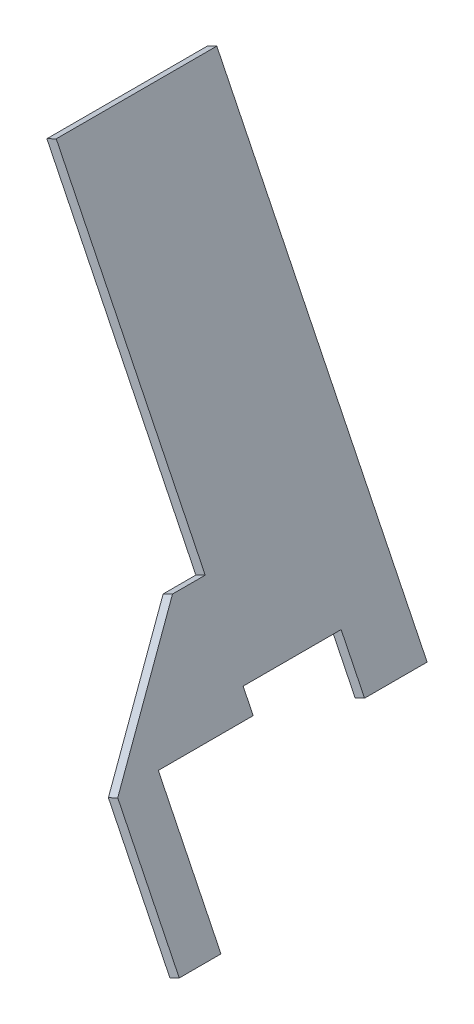
from build123d import *

# Parameters (mm, degrees)
BOSS_EXTRUDE1_DEPTH = 210.295833075
CUT_EXTRUDE3_DEPTH  = 2024.344561921
BOSS_EXTRUDE2_DEPTH = 77
SKETCH7_W           = 5
SKETCH7_H           = 30
BOSS_EXTRUDE4_DEPTH = 25.5


with BuildPart() as part:
    # Sketch2 → Boss-Extrude1 (new body)
    with BuildSketch(Plane.XY.offset(116.791940296)):
        Polygon((-1177.651750867, 1643.980030656), (-1173.163691186, 1646.183963573), (-1041.945008983, 1378.971984434), (-1046.433068663, 1376.768051516), align=None)
    extrude(amount=BOSS_EXTRUDE1_DEPTH)

    # Sketch5 → Cut-Extrude3 (cut, through all)
    with BuildSketch(Plane(origin=(-293.905010595, -144.326718837, 0), x_dir=(0, 0, 1), z_dir=(-0.8976119360459706, -0.4407865835841701, 0))):
        Polygon((132.47954497, 1831.677464024), (116.791940296, 1831.677464024), (116.791940296, 1994.749190054), (327.087773371, 1994.749190054), (327.087773371, 1623.434080327), (116.791940296, 1623.434080327), (116.791940296, 1779.483651489), (162.291940296, 1779.483651489), (162.291940296, 1711.327604599), (182.291940296, 1711.327604599), (182.291940296, 1778.260209904), align=None)
    extrude(amount=CUT_EXTRUDE3_DEPTH, mode=Mode.SUBTRACT)

    # Sketch6 → Boss-Extrude2 (add)
    with BuildSketch(Plane(origin=(0, 0, 116.791940296), x_dir=(-1, 0, 0), z_dir=(0, 0, -1))):
        Polygon((1087.597149779, 1460.594038789), (1083.109090099, 1462.797971707), (1172.730720222, 1645.302267261), (1177.218779902, 1643.098334343), align=None)
    extrude(amount=BOSS_EXTRUDE2_DEPTH)

    # Sketch7 → Boss-Extrude4 (add)
    with BuildSketch(Plane(origin=(-789.204079504, 1607.124690544, 0), x_dir=(0.8976119360459841, 0.44078658358414263, 0), z_dir=(0.44078658358414263, -0.8976119360459841, 0))):
        with Locations((-329.92992689, 54.791940296)):
            Rectangle(SKETCH7_W, SKETCH7_H)
    extrude(amount=BOSS_EXTRUDE4_DEPTH)


solid = part.part
